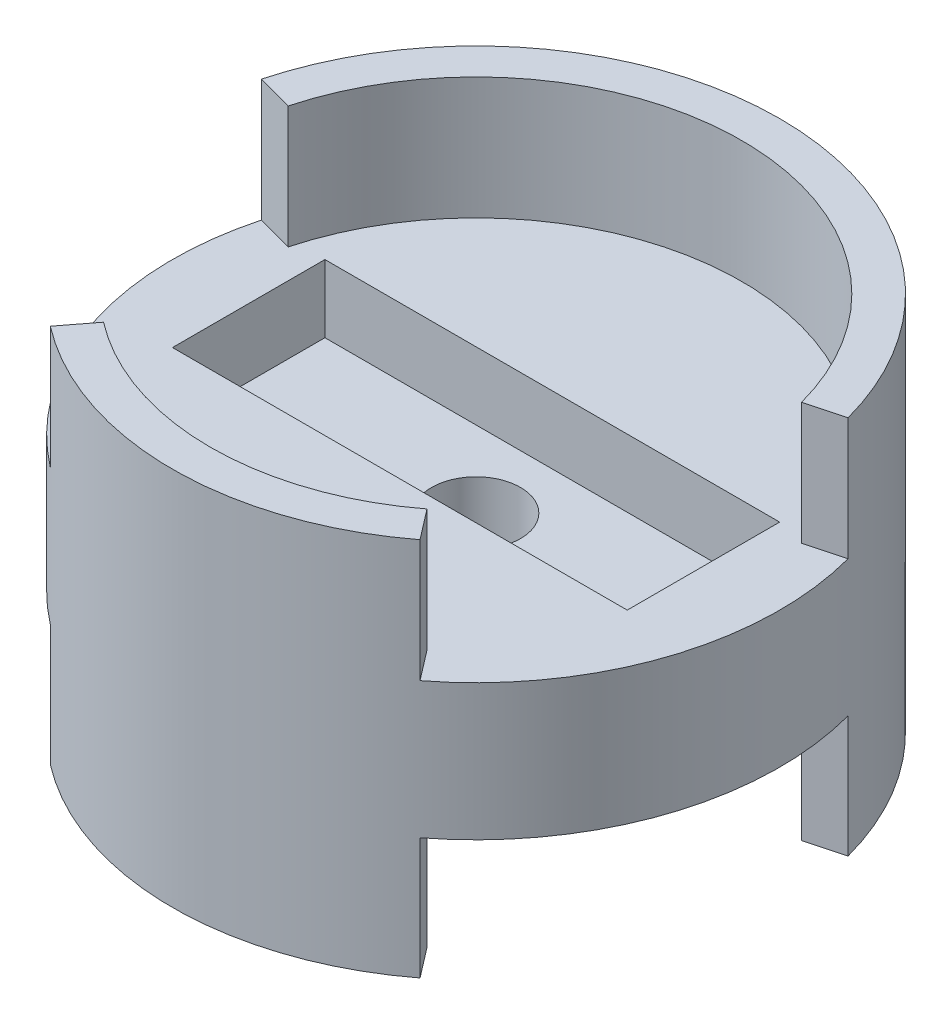
from build123d import *

# Parameters (mm, degrees)
SKETCH1_R           = 25.4
SKETCH1_W           = 38.0365
SKETCH1_H           = 12.7508
BOSS_EXTRUDE1_DEPTH = 5.6642
BOSS_EXTRUDE2_START = -5.715
SKETCH1_3_R         = 25.4
SKETCH1_3_R_2       = 3.71475
BOSS_EXTRUDE2_DEPTH = 5.715
BOSS_EXTRUDE3_DEPTH = 15.875


with BuildPart() as part:
    # Sketch1 → Boss-Extrude1 (new body)
    with BuildSketch(Plane(origin=(0, 0, 0), x_dir=(1, 0, 0), z_dir=(0, 1, 0))):
        Circle(SKETCH1_R)
        Rectangle(SKETCH1_W, SKETCH1_H, mode=Mode.SUBTRACT)
    extrude(amount=BOSS_EXTRUDE1_DEPTH)

    # Sketch1_3 → Boss-Extrude2 (add)
    with BuildSketch(Plane(origin=(0, 0, 0), x_dir=(1, 0, 0), z_dir=(0, 1, 0)).offset(BOSS_EXTRUDE2_START)):
        Circle(SKETCH1_3_R)
        Circle(SKETCH1_3_R_2, mode=Mode.SUBTRACT)
    extrude(amount=BOSS_EXTRUDE2_DEPTH)

    # Sketch2 → Boss-Extrude3 (add, symmetric)
    with BuildSketch(Plane(origin=(0, 0, 0), x_dir=(1, 0, 0), z_dir=(0, 1, 0))):
        with BuildLine():
            Line((21.467701, 5.752253), (24.534516, 6.574004))
            ThreePointArc((24.534516, 6.574004), (0, 25.4), (-24.534516, 6.574004))
            Line((-24.534516, 6.574004), (-21.467701, 5.752253))
            ThreePointArc((-21.467701, 5.752253), (0, 22.225), (21.467701, 5.752253))
        make_face()
        with BuildLine():
            Line((-13.529723, -17.632278), (-15.46254, -20.151175))
            ThreePointArc((-15.46254, -20.151175), (0, -25.4), (15.46254, -20.151175))
            Line((15.46254, -20.151175), (13.529723, -17.632278))
            ThreePointArc((13.529723, -17.632278), (0, -22.225), (-13.529723, -17.632278))
        make_face()
    extrude(amount=BOSS_EXTRUDE3_DEPTH, both=True)


solid = part.part
